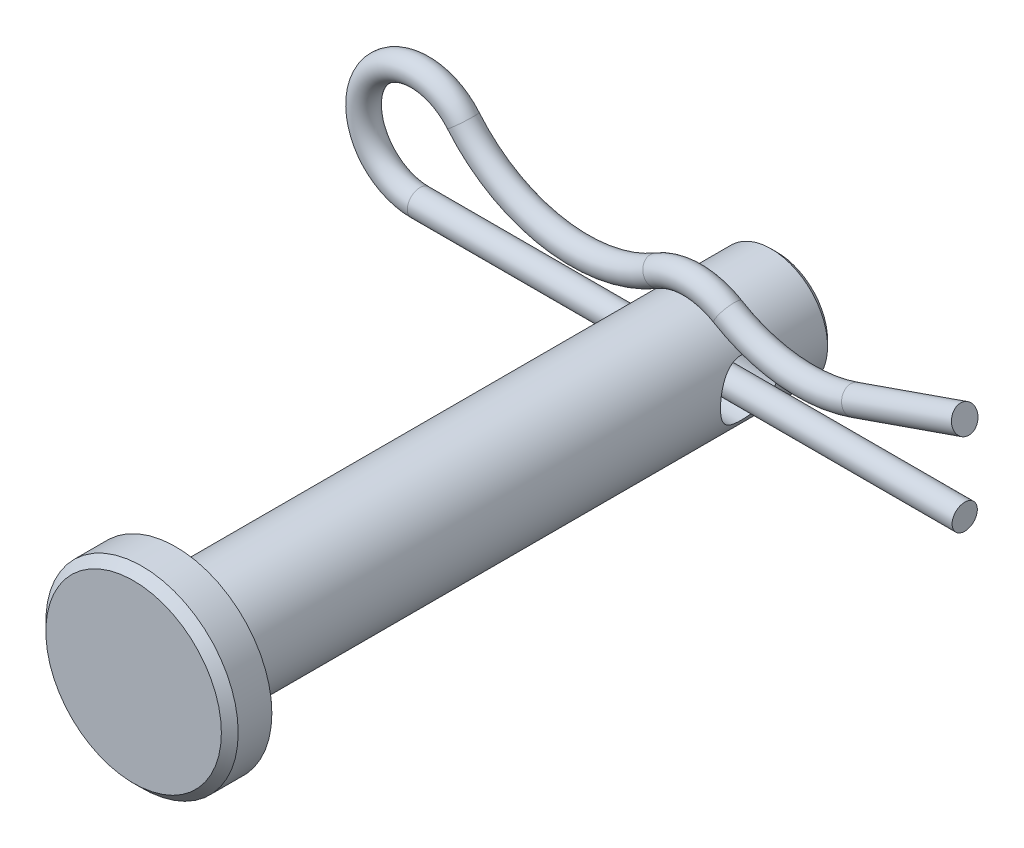
from build123d import *

# Parameters (mm, degrees)
SKETCH1_R           = 2.38125
EXTRUDE1_DEPTH      = 12.7
SKETCH2_R           = 4.064
EXTRUDE2_DEPTH      = 1.778
CHAMFER1_SIZE       = 0.3556
SKETCH3_R           = 1.190625
EXTRUDE3_DEPTH      = 5.064
EXTRUDE3_DEPTH_BACK = 5.064
CHAMFER2_SIZE       = 0.238125
SKETCH7_R           = 0.5334


with BuildPart() as part:
    # Sketch1 → Extrude1 (new body, symmetric)
    with BuildSketch(Plane.XY):
        Circle(SKETCH1_R)
    extrude(amount=EXTRUDE1_DEPTH, both=True)

    # Sketch2 → Extrude2 (add)
    with BuildSketch(Plane.XY.offset(12.7)):
        Circle(SKETCH2_R)
    extrude(amount=EXTRUDE2_DEPTH)

    # Chamfer1
    chamfer1_edges = [part.edges().sort_by_distance(p)[0] for p in [
        (-4.064, 0, 14.478),
    ]]
    chamfer(chamfer1_edges, length=CHAMFER1_SIZE)

    # Sketch3 → Extrude3 (cut, two sides)
    with BuildSketch(Plane(origin=(0, 0, 0), x_dir=(0, 0, -1), z_dir=(1, 0, 0))) as extrude3_sk:
        with Locations((9.128125, 0)):
            Circle(SKETCH3_R)
    extrude(amount=EXTRUDE3_DEPTH, mode=Mode.SUBTRACT)
    extrude(extrude3_sk.sketch, amount=-EXTRUDE3_DEPTH_BACK, mode=Mode.SUBTRACT)

    # Chamfer2
    chamfer2_edges = [part.edges().sort_by_distance(p)[0] for p in [
        (-2.38125, 0, -12.7),
    ]]
    chamfer(chamfer2_edges, length=CHAMFER2_SIZE)


with BuildPart() as body_2:
    # Sweep1: sweep along a path in Sketch6
    with BuildLine(Plane.XY.offset(-9.128125)) as sweep1_path:
        Line((11.509375, 0), (-11.509375, 0))
        ThreePointArc((-11.509375, 0), (-13.665265976, 3.392430331), (-9.678408448, 3.903719392))
        ThreePointArc((-9.678408448, 3.903719392), (-5.844791833, 1.691759471), (-1.493743003, 2.502781745))
        ThreePointArc((-1.493743003, 2.502781745), (0, 2.91465), (1.493743003, 2.502781745))
        ThreePointArc((1.493743003, 2.502781745), (4.120038067, 1.633068096), (6.867741763, 1.955483963))
        Line((6.867741763, 1.955483963), (11.509375, 3.571875))
    # Sketch7 → Sweep1 (sweep)
    with BuildSketch(Plane(origin=(11.509375, 0, -9.128125), x_dir=(0, 0, 1), z_dir=(-1, 0, 0))):
        Circle(SKETCH7_R)
    sweep(path=sweep1_path.line)


solid = Compound([part.part, body_2.part])
